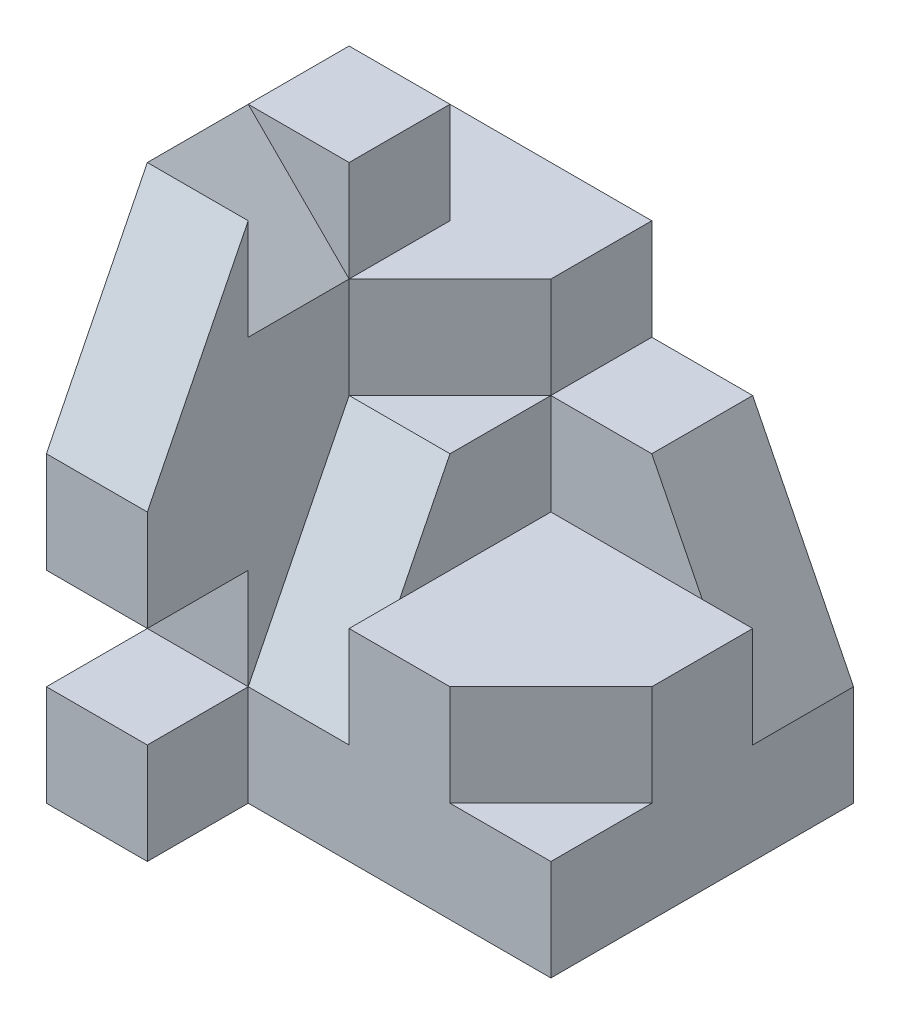
from build123d import *

# Parameters (mm, degrees)
SKETCH1_W           = 4
SKETCH1_H           = 5
BOSS_EXTRUDE1_DEPTH = 4
SKETCH2_W           = 3
SKETCH2_H           = 1
CUT_EXTRUDE1_DEPTH  = 6
SKETCH3_W           = 1
SKETCH3_H           = 1
CUT_EXTRUDE2_DEPTH  = 1
CUT_EXTRUDE3_DEPTH  = 1
CUT_EXTRUDE5_DEPTH  = 1
SKETCH6_W           = 2
SKETCH6_H           = 2
CUT_EXTRUDE6_DEPTH  = 2
CUT_EXTRUDE7_DEPTH  = 1
CUT_EXTRUDE8_DEPTH  = 1
CUT_EXTRUDE9_DEPTH  = 1
SKETCH12_W          = 1
SKETCH12_H          = 2.236067978
CUT_EXTRUDE10_DEPTH = 1
SKETCH14_W          = 1
SKETCH14_H          = 1.414213562
CUT_EXTRUDE11_DEPTH = 1


with BuildPart() as part:
    # Sketch1 → Boss-Extrude1 (new body)
    with BuildSketch(Plane.XY):
        Rectangle(SKETCH1_W, SKETCH1_H)
    extrude(amount=BOSS_EXTRUDE1_DEPTH)

    # Sketch2 → Cut-Extrude1 (cut, through all)
    with BuildSketch(Plane(origin=(0, 2.5, 0), x_dir=(1, 0, 0), z_dir=(0, 1, 0))):
        with Locations((0.5, -3.5)):
            Rectangle(SKETCH2_W, SKETCH2_H)
    extrude(amount=-CUT_EXTRUDE1_DEPTH, mode=Mode.SUBTRACT)

    # Sketch3 → Cut-Extrude2 (cut)
    with BuildSketch(Plane(origin=(-1, 0, 0), x_dir=(0, 0, -1), z_dir=(1, 0, 0))):
        with Locations((-3.5, -1)):
            Rectangle(SKETCH3_W, SKETCH3_H)
    extrude(amount=-CUT_EXTRUDE2_DEPTH, mode=Mode.SUBTRACT)

    # Sketch4 → Cut-Extrude3 (cut)
    with BuildSketch(Plane(origin=(-1, 0, 0), x_dir=(0, 0, -1), z_dir=(1, 0, 0))):
        Polygon((-3, 2.5), (-4, 0.5), (-4, 2.5), align=None)
    extrude(amount=-CUT_EXTRUDE3_DEPTH, mode=Mode.SUBTRACT)

    # Sketch5 → Cut-Extrude5 (cut)
    with BuildSketch(Plane(origin=(0, 2.5, 0), x_dir=(1, 0, 0), z_dir=(0, 1, 0))):
        Polygon((-2, 0), (-2, -1), (-1, -1), (-1, -3), (2, -3), (2, 0), align=None)
    extrude(amount=-CUT_EXTRUDE5_DEPTH, mode=Mode.SUBTRACT)

    # Sketch6 → Cut-Extrude6 (cut)
    with BuildSketch(Plane(origin=(0, 1.5, 0), x_dir=(1, 0, 0), z_dir=(0, 1, 0))):
        with Locations((1, -2)):
            Rectangle(SKETCH6_W, SKETCH6_H)
    extrude(amount=-CUT_EXTRUDE6_DEPTH, mode=Mode.SUBTRACT)

    # Sketch7 → Cut-Extrude7 (cut)
    with BuildSketch(Plane(origin=(0, -0.5, 0), x_dir=(1, 0, 0), z_dir=(0, 1, 0))):
        Polygon((2, -3), (2, -2), (1, -3), align=None)
    extrude(amount=-CUT_EXTRUDE7_DEPTH, mode=Mode.SUBTRACT)

    # Sketch8 → Cut-Extrude8 (cut)
    with BuildSketch(Plane(origin=(0, 0, 0), x_dir=(-1, 0, 0), z_dir=(0, 0, -1))):
        Polygon((-2, -1.5), (-2, 1.5), (0, 1.5), (0, 0.5), (-1, 0.5), align=None)
    extrude(amount=-CUT_EXTRUDE8_DEPTH, mode=Mode.SUBTRACT)

    # Sketch9 → Cut-Extrude9 (cut)
    with BuildSketch(Plane(origin=(0, 1.5, 0), x_dir=(1, 0, 0), z_dir=(0, 1, 0))):
        Polygon((0, -1), (-1, -2), (-1, -3), (0, -3), align=None)
    extrude(amount=-CUT_EXTRUDE9_DEPTH, mode=Mode.SUBTRACT)

    # Sketch12 → Cut-Extrude10 (cut)
    with BuildSketch(Plane(origin=(0, 0.9, 1.8), x_dir=(1, 0, 0), z_dir=(0, 0.447213595, 0.894427191))):
        with Locations((-0.5, -1.565247584)):
            Rectangle(SKETCH12_W, SKETCH12_H)
    extrude(amount=CUT_EXTRUDE10_DEPTH, mode=Mode.SUBTRACT)

    # Sketch14 → Cut-Extrude11 (cut)
    with BuildSketch(Plane(origin=(0.25, 0.25, 0), x_dir=(0, 0, 1), z_dir=(-0.707106781, -0.707106781, 0))):
        with Locations((2.5, 2.474873734)):
            Rectangle(SKETCH14_W, SKETCH14_H)
    extrude(amount=-CUT_EXTRUDE11_DEPTH, mode=Mode.SUBTRACT)


solid = part.part
